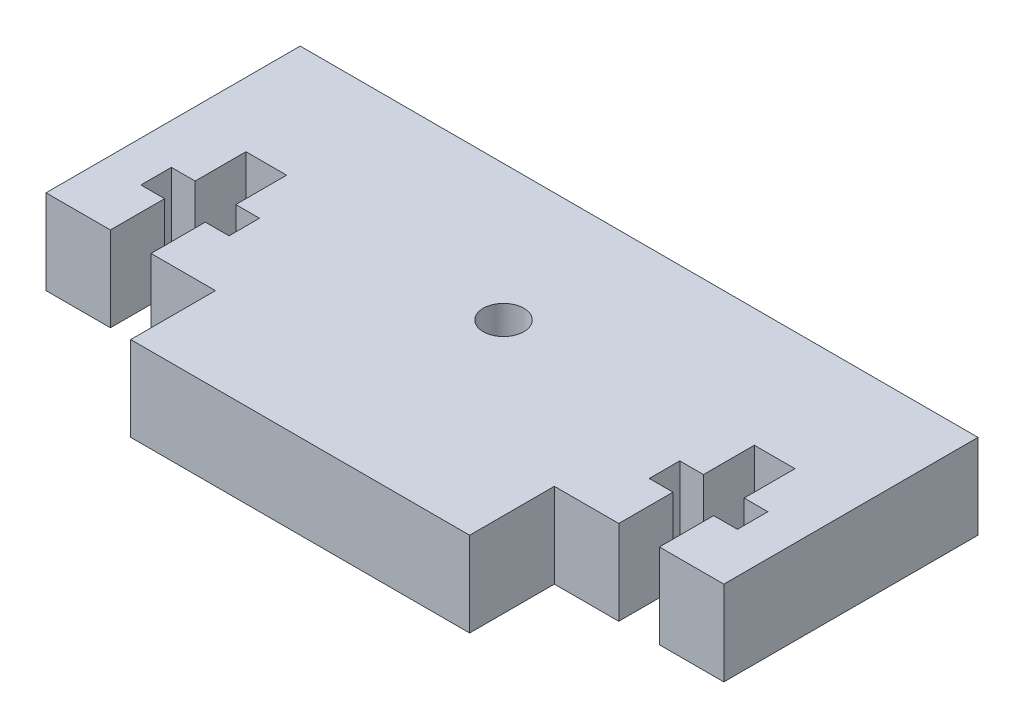
from build123d import *

# Parameters (mm, degrees)
BOSS_EXTRUDE1_DEPTH = 6.35
SKETCH2_R           = 1.524
CUT_EXTRUDE1_DEPTH  = 7.35


with BuildPart() as part:
    # Sketch1 → Boss-Extrude1 (new body)
    with BuildSketch(Plane(origin=(0, 0, 0), x_dir=(1, 0, 0), z_dir=(0, 1, 0))):
        Polygon((50.8, 0), (0, 0), (0, -19.05), (4.826, -19.05), (4.826, -14.986), (3.048, -14.986), (3.048, -12.7), (4.826, -12.7), (4.826, -8.89), (7.874, -8.89), (7.874, -12.7), (9.652, -12.7), (9.652, -14.986), (7.874, -14.986), (7.874, -19.05), (12.7, -19.05), (12.7, -25.4), (38.1, -25.4), (38.1, -19.05), (42.926, -19.05), (42.926, -14.986), (41.148, -14.986), (41.148, -12.7), (42.926, -12.7), (42.926, -8.89), (45.974, -8.89), (45.974, -12.7), (47.752, -12.7), (47.752, -14.986), (45.974, -14.986), (45.974, -19.05), (50.8, -19.05), align=None)
    extrude(amount=BOSS_EXTRUDE1_DEPTH)

    # Sketch2 → Cut-Extrude1 (cut, through all)
    with BuildSketch(Plane(origin=(0, 6.35, 0), x_dir=(1, 0, 0), z_dir=(0, 1, 0))):
        with Locations((25.4, -10.16)):
            Circle(SKETCH2_R)
    extrude(amount=-CUT_EXTRUDE1_DEPTH, mode=Mode.SUBTRACT)


solid = part.part
